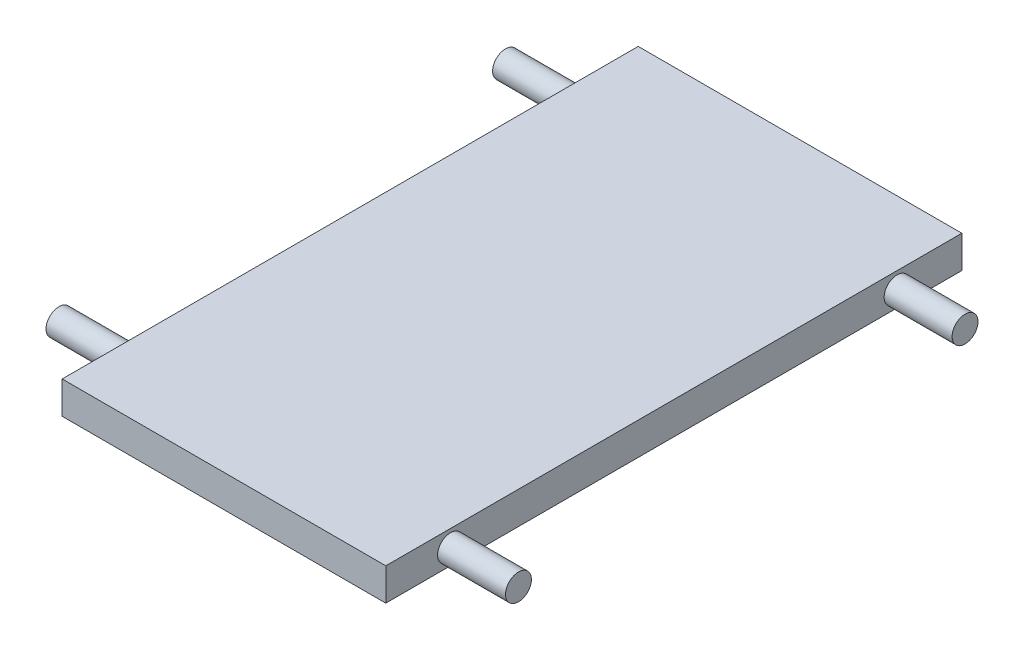
from build123d import *

# Parameters (mm, degrees)
SKETCH1_W               = 500
SKETCH1_H               = 890
BOSS_EXTRUDE1_DEPTH     = 50
SKETCH2_R               = 20
BOSS_EXTRUDE2_DEPTH     = 105
MIRROR2_COPY_1_SKETCH_R = 20
MIRROR2_COPY_1_DEPTH    = 105


with BuildPart() as part:
    # Sketch1 → Boss-Extrude1 (new body)
    with BuildSketch(Plane(origin=(0, 0, 0), x_dir=(1, 0, 0), z_dir=(0, 1, 0))):
        Rectangle(SKETCH1_W, SKETCH1_H)
    extrude(amount=BOSS_EXTRUDE1_DEPTH)

    # Sketch2 → Boss-Extrude2 (add)
    with BuildSketch(Plane(origin=(250, 0, 0), x_dir=(0, 0, -1), z_dir=(1, 0, 0))):
        with Locations((345, 24.274325974)):
            Circle(SKETCH2_R)
    boss_extrude2 = extrude(amount=BOSS_EXTRUDE2_DEPTH)

    # Mirror1: Boss-Extrude2 across plane
    add(boss_extrude2.mirror(Plane.XY))

    # Mirror2: Boss-Extrude2 across plane
    add(boss_extrude2.mirror(Plane(origin=(0, 0, 0), x_dir=(0, 0, 1), z_dir=(1, 0, 0))))

    # Mirror2 copy 1 sketch → Mirror2 copy 1 (add)
    with BuildSketch(Plane.ZY.offset(250)):
        with Locations((345, 24.274325974)):
            Circle(MIRROR2_COPY_1_SKETCH_R)
    extrude(amount=MIRROR2_COPY_1_DEPTH)


solid = part.part
